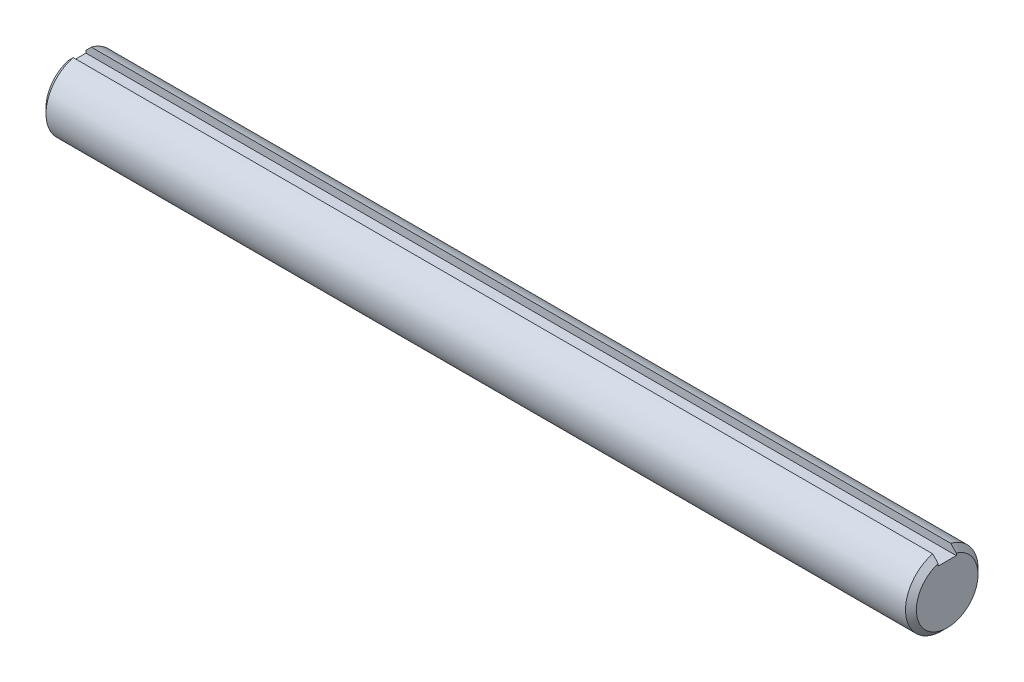
from build123d import *

# Parameters (mm, degrees)
SKETCH1_R           = 12.7
EXTRUDE1_DEPTH      = 152.4
CHAMFER1_SIZE       = 1.905
SKETCH3_W           = 6.35
SKETCH3_H           = 3.175
EXTRUDE2_DEPTH      = 153.4
EXTRUDE2_DEPTH_BACK = 153.4


with BuildPart() as part:
    # Sketch1 → Extrude1 (new body, symmetric)
    with BuildSketch(Plane(origin=(0, 0, 0), x_dir=(0, 0, -1), z_dir=(1, 0, 0))):
        Circle(SKETCH1_R)
    extrude(amount=EXTRUDE1_DEPTH, both=True)

    # Chamfer1
    chamfer1_edges = [part.edges().sort_by_distance(p)[0] for p in [
        (-152.4, 0, 12.7),
        (152.4, 0, 12.7),
    ]]
    chamfer(chamfer1_edges, length=CHAMFER1_SIZE)

    # Sketch3 → Extrude2 (cut, two sides)
    with BuildSketch(Plane(origin=(0, 0, 0), x_dir=(0, 0, -1), z_dir=(1, 0, 0))) as extrude2_sk:
        with Locations((0, 11.1125)):
            Rectangle(SKETCH3_W, SKETCH3_H)
    extrude(amount=EXTRUDE2_DEPTH, mode=Mode.SUBTRACT)
    extrude(extrude2_sk.sketch, amount=-EXTRUDE2_DEPTH_BACK, mode=Mode.SUBTRACT)


solid = part.part
